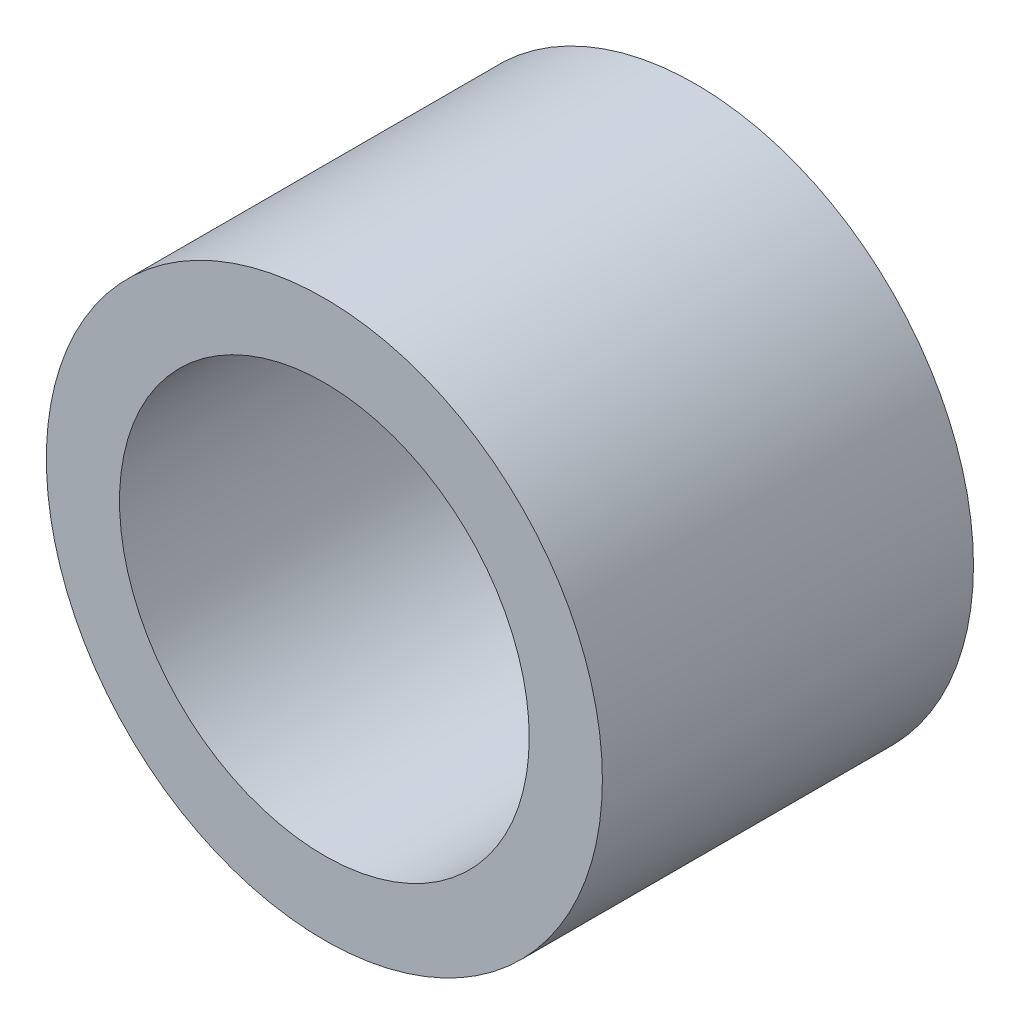
from build123d import *

# Parameters (mm, degrees)
SKETCH1_R           = 4.826
SKETCH1_R_2         = 3.556
BOSS_EXTRUDE1_DEPTH = 6.44144


with BuildPart() as part:
    # Sketch1 → Boss-Extrude1 (new body)
    with BuildSketch(Plane.XY):
        Circle(SKETCH1_R)
        Circle(SKETCH1_R_2, mode=Mode.SUBTRACT)
    extrude(amount=BOSS_EXTRUDE1_DEPTH)


solid = part.part
